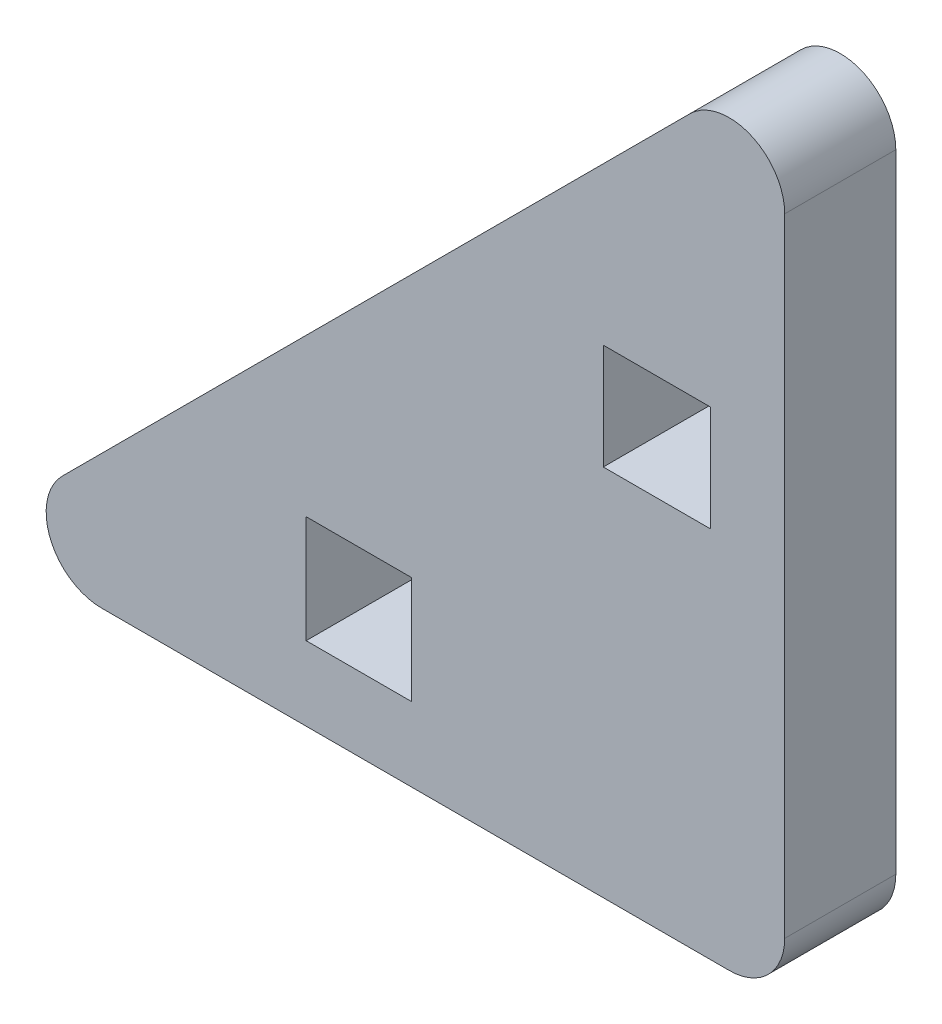
from build123d import *

# Parameters (mm, degrees)
SKETCH_1_W      = 2.85
SKETCH_1_H      = 2.9
SKETCH_1_W_2    = 2.9
SKETCH_1_H_2    = 2.85
EXTRUDE_1_DEPTH = 3
FILLET_1_R      = 1.5


with BuildPart() as part:
    # Эскиз1 → Бобышка-Вытянуть1 (new body)
    with BuildSketch(Plane.XY):
        Polygon((0, 22.067640687), (0, 0), (-22.067640687, 0), align=None)
        with Locations((-11.5, 3.45)):
            Rectangle(SKETCH_1_W, SKETCH_1_H, mode=Mode.SUBTRACT)
        with Locations((-3.45, 11.5)):
            Rectangle(SKETCH_1_W_2, SKETCH_1_H_2, mode=Mode.SUBTRACT)
    extrude(amount=EXTRUDE_1_DEPTH)

    # Скругление1
    fillet_1_edges = [part.edges().sort_by_distance(p)[0] for p in [
        (0, 0, 1.5),
        (-22.067640687, 0, 1.5),
        (0, 22.067640687, 1.5),
    ]]
    fillet(fillet_1_edges, radius=FILLET_1_R)


solid = part.part
